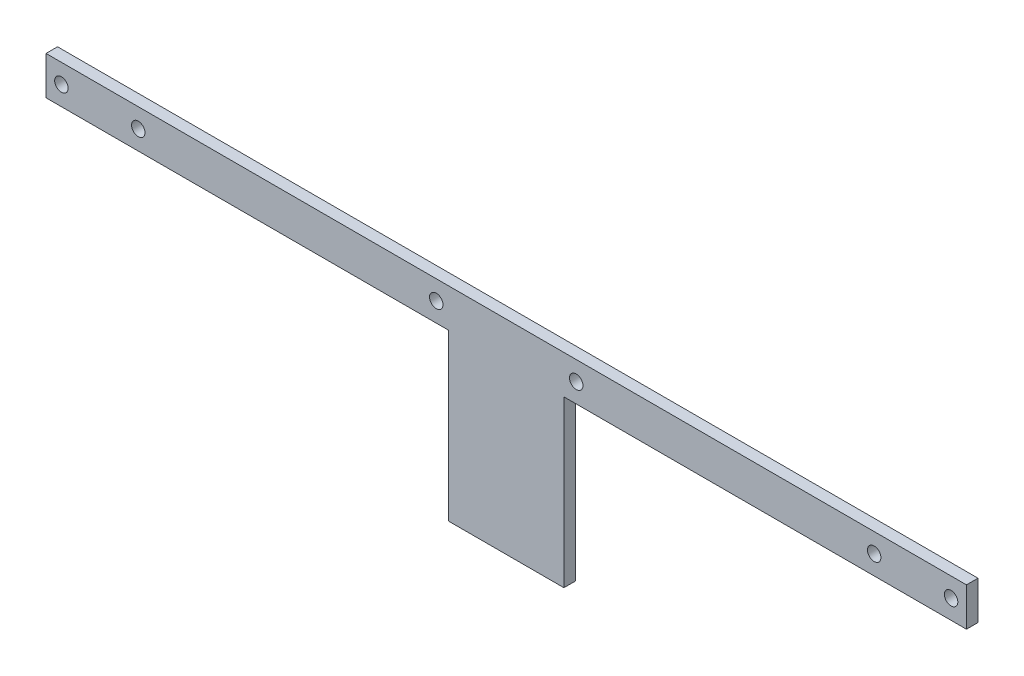
from build123d import *

# Parameters (mm, degrees)
SKETCH1_R           = 1.75
BOSS_EXTRUDE1_DEPTH = 3


with BuildPart() as part:
    # Sketch1 → Boss-Extrude1 (new body)
    with BuildSketch(Plane.XY):
        Polygon((0, 0), (0, 10), (239.4, 10), (239.4, 0), (134.7, 0), (134.7, -43), (104.7, -43), (104.7, 0), align=None)
        with Locations((4, 5)):
            Circle(SKETCH1_R, mode=Mode.SUBTRACT)
        with Locations((24, 5)):
            Circle(SKETCH1_R, mode=Mode.SUBTRACT)
        with Locations((235.4, 5)):
            Circle(SKETCH1_R, mode=Mode.SUBTRACT)
        with Locations((215.4, 5)):
            Circle(SKETCH1_R, mode=Mode.SUBTRACT)
        with Locations((101.5, 5)):
            Circle(SKETCH1_R, mode=Mode.SUBTRACT)
        with Locations((137.9, 5)):
            Circle(SKETCH1_R, mode=Mode.SUBTRACT)
    extrude(amount=BOSS_EXTRUDE1_DEPTH)


solid = part.part
